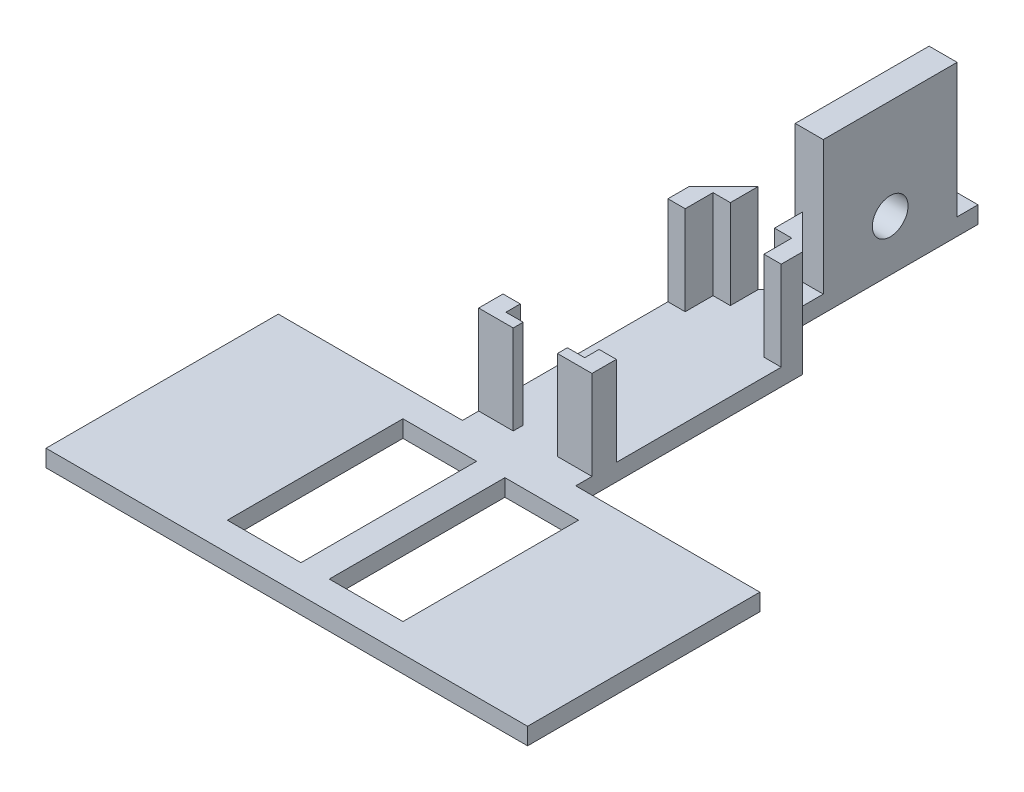
from build123d import *

# Parameters (mm, degrees)
SKETCH1_W           = 16.51
SKETCH1_H           = 39.37
BOSS_EXTRUDE1_DEPTH = 3.81
SKETCH2_W           = 6.281845558
SKETCH2_H           = 29.999999944
BOSS_EXTRUDE2_DEPTH = 30
CUT_EXTRUDE1_REACH  = 59.2
SKETCH3_R           = 4
BOSS_EXTRUDE3_DEPTH = 20


with BuildPart() as part:
    # Sketch1 → Boss-Extrude1 (new body)
    with BuildSketch(Plane(origin=(0, 0, 0), x_dir=(1, 0, 0), z_dir=(0, 1, 0))):
        Polygon((-53.975, 20.680273282), (-53.975, -31.389726718), (53.975, -31.389726718), (53.975, 20.680273282), (12.7, 20.680273282), (12.7, 71.480273282), (3.225157137, 80.955116145), (3.225157137, 120.325116145), (-3.056688421, 120.325116145), (-3.056688421, 81.123584861), (-12.7, 71.480273282), (-12.7, 20.680273282), align=None)
        with Locations((-11.43, -5.354726718)):
            Rectangle(SKETCH1_W, SKETCH1_H, mode=Mode.SUBTRACT)
        with Locations((11.43, -5.354726718)):
            Rectangle(SKETCH1_W, SKETCH1_H, mode=Mode.SUBTRACT)
    extrude(amount=BOSS_EXTRUDE1_DEPTH)

    # Sketch2 → Boss-Extrude2 (add)
    with BuildSketch(Plane(origin=(0, 3.81, 0), x_dir=(1, 0, 0), z_dir=(0, 1, 0))):
        with Locations((0.084234358, 100.640116145)):
            Rectangle(SKETCH2_W, SKETCH2_H)
    extrude(amount=BOSS_EXTRUDE2_DEPTH)

    # Sketch3 → Cut-Extrude1 (cut, up to next)
    with BuildSketch(Plane(origin=(3.225157137, 0, 0), x_dir=(0, 0, -1), z_dir=(1, 0, 0)), mode=Mode.PRIVATE) as cut_extrude1_sk1:
        with Locations((100.640116145, 11.43)):
            Circle(SKETCH3_R)
    cut_extrude1_tool1 = extrude(cut_extrude1_sk1.sketch, amount=-CUT_EXTRUDE1_REACH, mode=Mode.PRIVATE) & part.part
    add(cut_extrude1_tool1.solids().sort_by_distance((3.225157, 11.43, -100.640116))[0], mode=Mode.SUBTRACT)

    # Sketch6 → Boss-Extrude3 (add)
    with BuildSketch(Plane(origin=(0, 3.81, 0), x_dir=(1, 0, 0), z_dir=(0, 1, 0))):
        Polygon((-8.128, 24.319391954), (-4.952973996, 24.319391954), (-4.952973996, 26.561602149), (-8.829142948, 26.561602149), (-8.829142948, 29.779456866), (-12.7, 29.779456866), (-12.7, 24.319391954), align=None)
        Polygon((12.7, 24.319391954), (8.128, 24.319391954), (4.952973996, 24.319391954), (4.952973996, 26.561602149), (8.829142948, 26.561602149), (8.829142948, 29.779456866), (12.7, 29.779456866), align=None)
        Polygon((-4.952973996, 79.227299287), (-12.7, 71.480273282), (-12.7, 66.743012955), (-8.829142948, 66.743012955), (-8.829142948, 72.988681503), (-4.952973996, 72.988681503), align=None)
        Polygon((4.952973996, 72.988681503), (4.952973996, 79.227299287), (12.7, 71.480273282), (12.7, 66.743012955), (8.829142948, 66.743012955), (8.829142948, 72.988681503), align=None)
    extrude(amount=BOSS_EXTRUDE3_DEPTH)


solid = part.part
